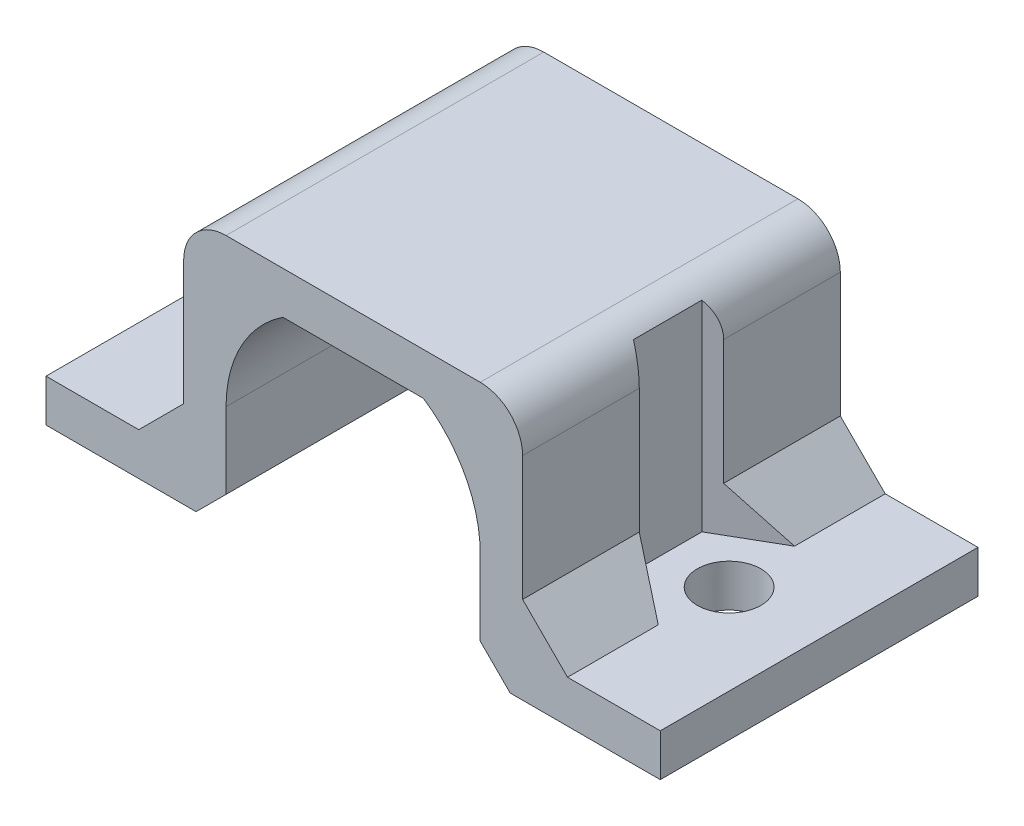
from build123d import *

# Parameters (mm, degrees)
SALIENTE_EXTRUIR1_DEPTH = 7.5
REDONDEO1_R             = 2
CORTAR_EXTRUIR2_DEPTH   = 10
CROQUIS4_R              = 1.5
CORTAR_EXTRUIR3_DEPTH   = 11


with BuildPart() as part:
    # Croquis1 → Saliente-Extruir1 (new body, symmetric)
    with BuildSketch(Plane.XY):
        with BuildLine():
            Line((14.5, 0), (7.414213562, 0))
            Line((7.414213562, 0), (6, 1.414213562))
            Line((6, 1.414213562), (6, 5))
            ThreePointArc((6, 5), (5.286764074, 7.837274331), (3.31662479, 10))
            Line((3.31662479, 10), (-3.31662479, 10))
            ThreePointArc((-3.31662479, 10), (-5.286764074, 7.837274331), (-6, 5))
            Line((-6, 5), (-6, 1.414213562))
            Line((-6, 1.414213562), (-7.414213562, 0))
            Line((-7.414213562, 0), (-14.5, 0))
            Line((-14.5, 0), (-14.5, 2))
            Line((-14.5, 2), (-10.121320344, 2))
            Line((-10.121320344, 2), (-8, 4.121320344))
            Line((-8, 4.121320344), (-8, 12))
            Line((-8, 12), (8, 12))
            Line((8, 12), (8, 4.121320344))
            Line((8, 4.121320344), (10.121320344, 2))
            Line((10.121320344, 2), (14.5, 2))
            Line((14.5, 2), (14.5, 0))
        make_face()
    extrude(amount=SALIENTE_EXTRUIR1_DEPTH, both=True)

    # Redondeo1
    redondeo1_edges = [part.edges().sort_by_distance(p)[0] for p in [
        (-8, 12, 0),
        (8, 12, 0),
    ]]
    fillet(redondeo1_edges, radius=REDONDEO1_R)

    # Croquis3 → Cortar-Extruir2 (cut)
    with BuildSketch(Plane(origin=(0, 12, 0), x_dir=(1, 0, 0), z_dir=(0, 1, 0))):
        Polygon((-10.15, -3.233161507), (-7.35, -1.616580754), (-7.35, 1.616580754), (-10.15, 3.233161507), (-12.95, 1.616580754), (-12.95, -1.616580754), align=None)
        Polygon((12.95, -1.616580754), (10.15, -3.233161507), (7.35, -1.616580754), (7.35, 1.616580754), (10.15, 3.233161507), (12.95, 1.616580754), align=None)
    extrude(amount=-CORTAR_EXTRUIR2_DEPTH, mode=Mode.SUBTRACT)

    # Croquis4 → Cortar-Extruir3 (cut)
    with BuildSketch(Plane.XZ):
        with Locations((-10.25, 0)):
            Circle(CROQUIS4_R)
        with Locations((10.25, 0)):
            Circle(CROQUIS4_R)
    extrude(amount=-CORTAR_EXTRUIR3_DEPTH, mode=Mode.SUBTRACT)


solid = part.part
